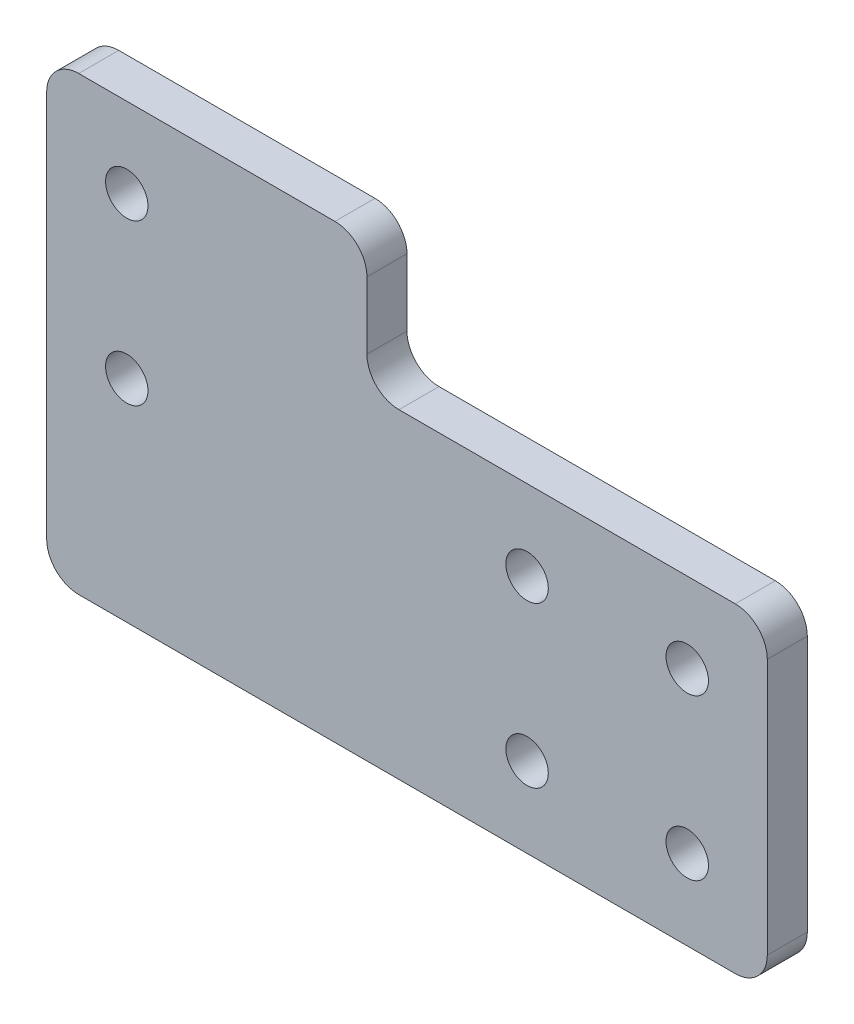
from build123d import *

# Parameters (mm, degrees)
END_CAP_SKETCH_R        = 2.65
EXTRUDE_THICKNESS_DEPTH = 5


with BuildPart() as part:
    # End Cap Sketch → Extrude Thickness (new body)
    with BuildSketch(Plane.XY):
        with BuildLine():
            Line((-66, -20), (16, -20))
            ThreePointArc((16, -20), (18.828427125, -18.828427125), (20, -16))
            Line((20, -16), (20, 16))
            ThreePointArc((20, 16), (18.828427125, 18.828427125), (16, 20))
            Line((16, 20), (-26, 20))
            ThreePointArc((-26, 20), (-28.828427125, 21.171572875), (-30, 24))
            Line((-30, 24), (-30, 32.365))
            ThreePointArc((-30, 32.365), (-31.171572875, 35.193427125), (-34, 36.365))
            Line((-34, 36.365), (-66, 36.365))
            ThreePointArc((-66, 36.365), (-68.828427125, 35.193427125), (-70, 32.365))
            Line((-70, 32.365), (-70, -16))
            ThreePointArc((-70, -16), (-68.828427125, -18.828427125), (-66, -20))
        make_face()
        with Locations((-10, 10)):
            Circle(END_CAP_SKETCH_R, mode=Mode.SUBTRACT)
        with Locations((-10, -10)):
            Circle(END_CAP_SKETCH_R, mode=Mode.SUBTRACT)
        with Locations((10, 10)):
            Circle(END_CAP_SKETCH_R, mode=Mode.SUBTRACT)
        with Locations((10, -10)):
            Circle(END_CAP_SKETCH_R, mode=Mode.SUBTRACT)
        with Locations((-60, 26.365)):
            Circle(END_CAP_SKETCH_R, mode=Mode.SUBTRACT)
        with Locations((-60, 6.365)):
            Circle(END_CAP_SKETCH_R, mode=Mode.SUBTRACT)
    extrude(amount=EXTRUDE_THICKNESS_DEPTH)


solid = part.part
